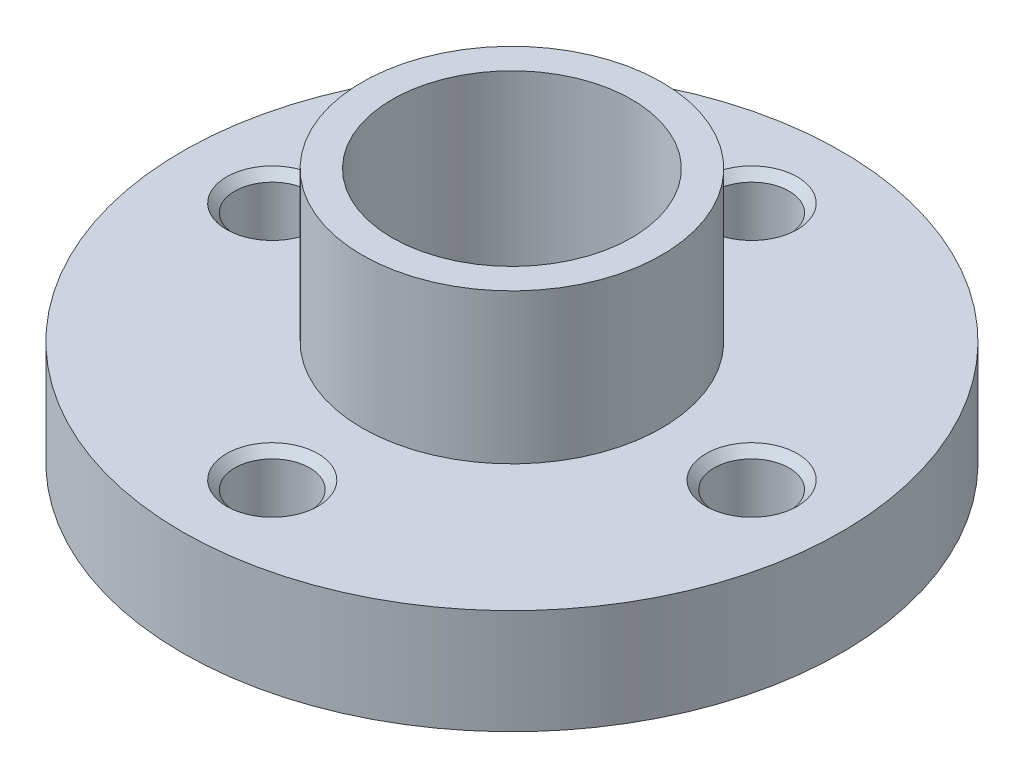
from build123d import *

# Parameters (mm, degrees)
SKETCH_1_R                   = 11
EXTRUDE_1_DEPTH              = 3.5
SKETCH_2_R                   = 5
EXTRUDE_2_DEPTH              = 5
EXTRUDE_2_DEPTH_BACK         = 5.5
SKETCH_3_R                   = 1.15
CUT_EXTRUDE_1_DEPTH          = 5
SKETCH_4_R                   = 4
CUT_EXTRUDE_2_DEPTH          = 11.5
HOLE_WIZARD_M3_1_D           = 2.5
HOLE_WIZARD_M3_1_DEPTH       = 8.5
HOLE_WIZARD_M3_1_CSINK_D     = 3.05
HOLE_WIZARD_M3_1_CSINK_ANGLE = 90
HOLE_WIZARD_M3_1_TIP         = 0.751075774


with BuildPart() as part:
    # 草图1 → 凸台-拉伸1 (new body)
    with BuildSketch(Plane(origin=(0, 0, 0), x_dir=(1, 0, 0), z_dir=(0, 1, 0))):
        Circle(SKETCH_1_R)
    extrude(amount=EXTRUDE_1_DEPTH)

    # 草图2 → 凸台-拉伸2 (add, two sides)
    with BuildSketch(Plane(origin=(0, 3.5, 0), x_dir=(1, 0, 0), z_dir=(0, 1, 0))) as extrude_2_sk:
        Circle(SKETCH_2_R)
    extrude(amount=EXTRUDE_2_DEPTH)
    extrude(extrude_2_sk.sketch, amount=-EXTRUDE_2_DEPTH_BACK)

    # 草图3 → 切除-拉伸1 (cut)
    with BuildSketch(Plane(origin=(0, 3.5, 0), x_dir=(1, 0, 0), z_dir=(0, 1, 0))):
        with Locations((0, 8)):
            Circle(SKETCH_3_R)
        with Locations((8, 0)):
            Circle(SKETCH_3_R)
        with Locations((0, -8)):
            Circle(SKETCH_3_R)
        with Locations((-8, 0)):
            Circle(SKETCH_3_R)
    extrude(amount=-CUT_EXTRUDE_1_DEPTH, mode=Mode.SUBTRACT)

    # 草图4 → 切除-拉伸2 (cut, through all)
    with BuildSketch(Plane(origin=(0, 8.5, 0), x_dir=(1, 0, 0), z_dir=(0, 1, 0))):
        Circle(SKETCH_4_R)
    extrude(amount=-CUT_EXTRUDE_2_DEPTH, mode=Mode.SUBTRACT)

    # M3 螺纹孔1
    with Locations(Plane(origin=(0, 3.5, 0), x_dir=(1, 0, 0), z_dir=(0, 1, 0))):
        with Locations((0, 8), (8, 0), (0, -8), (-8, 0)):
            CounterSinkHole(HOLE_WIZARD_M3_1_D / 2, HOLE_WIZARD_M3_1_CSINK_D / 2, depth=HOLE_WIZARD_M3_1_DEPTH, counter_sink_angle=HOLE_WIZARD_M3_1_CSINK_ANGLE)
            with Locations((0, 0, -(HOLE_WIZARD_M3_1_DEPTH + HOLE_WIZARD_M3_1_TIP / 2))):  # 118° drill point
                Cone(0, HOLE_WIZARD_M3_1_D / 2, HOLE_WIZARD_M3_1_TIP, mode=Mode.SUBTRACT)


solid = part.part
